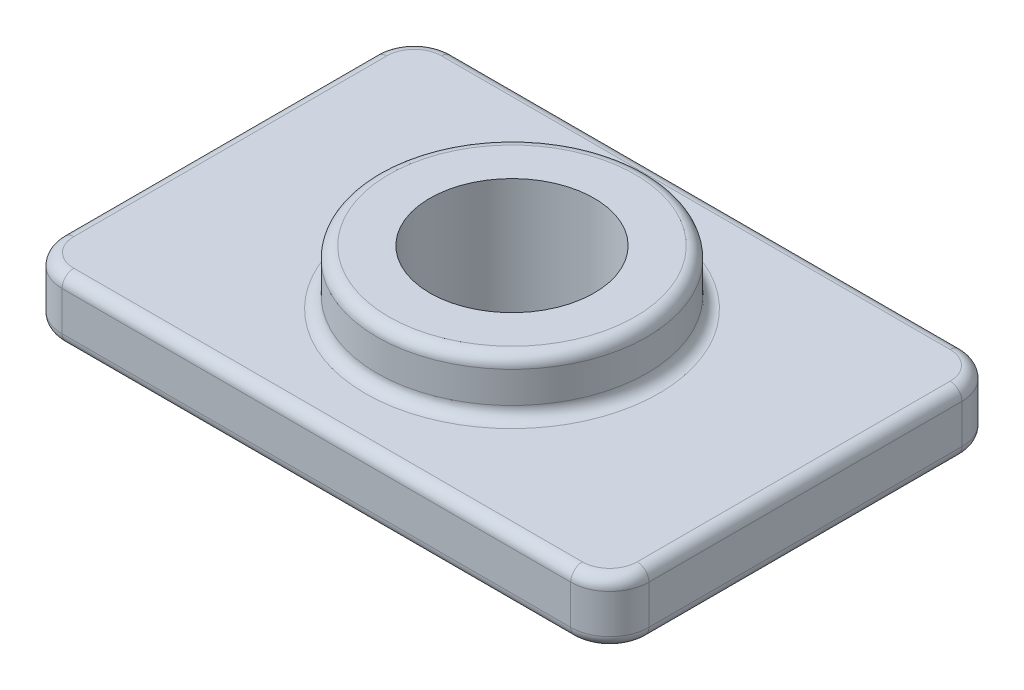
from build123d import *

# Parameters (mm, degrees)
BOSS_EXTRUDE1_DEPTH         = 1.6
SKETCH2_R                   = 3.45
BOSS_EXTRUDE2_DEPTH         = 1.4
TAP_DRILL_FOR_M5X0_8_TAP1_D = 4.2
FILLET2_R                   = 0.3


with BuildPart() as part:
    # Sketch1 → Boss-Extrude1 (new body)
    with BuildSketch(Plane(origin=(0, 0, 0), x_dir=(1, 0, 0), z_dir=(0, 1, 0))):
        with BuildLine():
            Line((1, 0), (14, 0))
            ThreePointArc((14, 0), (14.707106781, 0.292893219), (15, 1))
            Line((15, 1), (15, 9))
            ThreePointArc((15, 9), (14.707106781, 9.707106781), (14, 10))
            Line((14, 10), (1, 10))
            ThreePointArc((1, 10), (0.292893219, 9.707106781), (0, 9))
            Line((0, 9), (0, 1))
            ThreePointArc((0, 1), (0.292893219, 0.292893219), (1, 0))
        make_face()
    extrude(amount=BOSS_EXTRUDE1_DEPTH)

    # Sketch2 → Boss-Extrude2 (add)
    with BuildSketch(Plane(origin=(0, 1.6, 0), x_dir=(1, 0, 0), z_dir=(0, 1, 0))):
        with Locations((7.5, 5)):
            Circle(SKETCH2_R)
    extrude(amount=BOSS_EXTRUDE2_DEPTH)

    # Tap Drill for M5x0.8 Tap1 (through all)
    with Locations(Plane(origin=(7.5, 3, -5), x_dir=(0, 0, 1), z_dir=(0, 1, 0))):
        with Locations((0, 0)):
            Hole(TAP_DRILL_FOR_M5X0_8_TAP1_D / 2)

    # Fillet2
    fillet2_edges = [part.edges().sort_by_distance(p)[0] for p in [
        (14.707106781, 1.6, -0.292893219),
        (7.5, 0, 0),
        (0.292893219, 0, -0.292893219),
        (15, 1.6, -5),
        (14.707106781, 1.6, -9.707106781),
        (7.5, 1.6, -10),
        (0.292893219, 1.6, -9.707106781),
        (4.05, 1.6, -5),
        (4.05, 3, -5),
        (0, 1.6, -5),
        (0.292893219, 1.6, -0.292893219),
        (7.5, 1.6, 0),
        (0, 0, -5),
        (0.292893219, 0, -9.707106781),
        (7.5, 0, -10),
        (14.707106781, 0, -9.707106781),
        (15, 0, -5),
        (14.707106781, 0, -0.292893219),
    ]]
    fillet(fillet2_edges, radius=FILLET2_R)


solid = part.part
